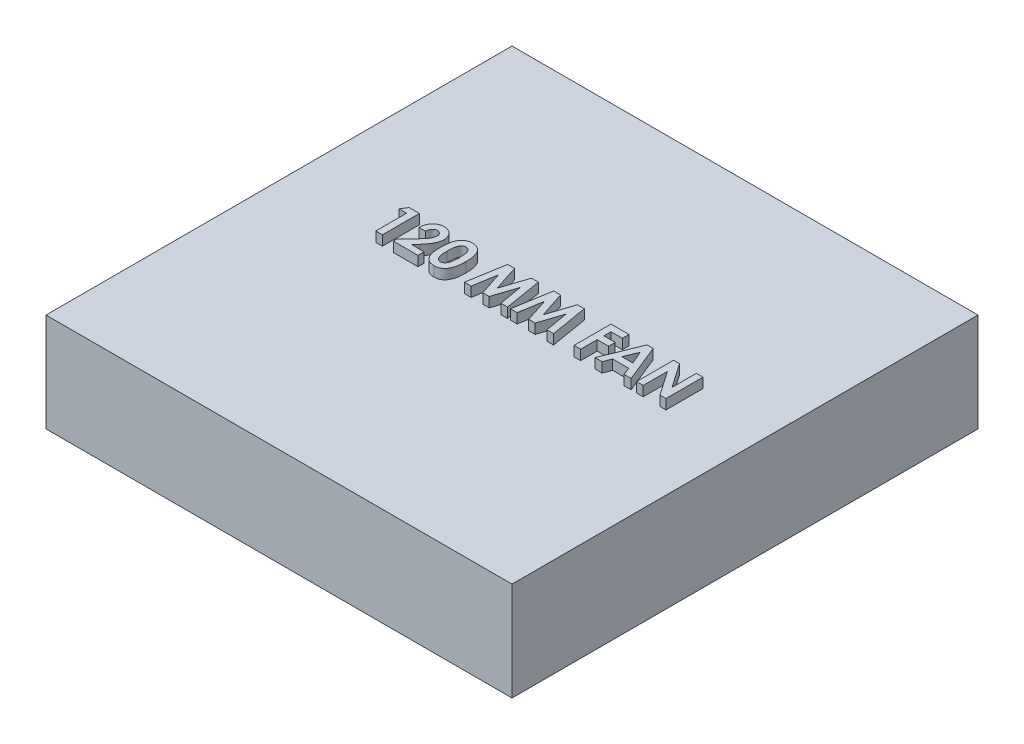
from build123d import *

# Parameters (mm, degrees)
SKETCH1_W           = 120
SKETCH1_H           = 120
BOSS_EXTRUDE1_DEPTH = 25.4
BOSS_EXTRUDE2_DEPTH = 2.54


with BuildPart() as part:
    # Sketch1 → Boss-Extrude1 (new body)
    with BuildSketch(Plane(origin=(0, 0, 0), x_dir=(1, 0, 0), z_dir=(0, 1, 0))):
        Rectangle(SKETCH1_W, SKETCH1_H)
    extrude(amount=BOSS_EXTRUDE1_DEPTH)

    # Sketch2 → Boss-Extrude2 (add)
    with BuildSketch(Plane(origin=(0, 25.4, 0), x_dir=(1, 0, 0), z_dir=(0, 1, 0))):
        Polygon((-34.68545046, 8.193229377), (-32.042797215, 8.193229377), (-32.042797215, -1.331770623), (-33.7524126, -1.331770623), (-33.7524126, 6.605729377), (-35.706258753, 6.605729377), align=None)
        with BuildLine():
            Line((-27.280297215, 5.018229377), (-28.9899126, 5.018229377))
            add(Edge.make_bspline(
                [(-28.9899126, 5.018229377), (-28.982529033, 5.147552736), (-28.968101987, 5.400242816), (-28.910714845, 5.767283247), (-28.833818044, 6.114096094), (-28.731189054, 6.439468166), (-28.602229014, 6.743281234), (-28.450256397, 7.026571013), (-28.271388648, 7.287845977), (-28.069432661, 7.52584611), (-27.847817093, 7.739358226), (-27.611142901, 7.92867148), (-27.355789834, 8.084888014), (-27.086423402, 8.213439758), (-26.803089471, 8.316146629), (-26.50310726, 8.384814483), (-26.189074174, 8.431317026), (-25.974093098, 8.435386185), (-25.864521975, 8.437460146)],
                knots=[0, 0, 0, 0, 0.000388391, 0.000758892, 0.001112999, 0.001453339, 0.001780797, 0.002101804, 0.00241617, 0.002728887, 0.003036551, 0.00333812, 0.003636247, 0.003932389, 0.004232342, 0.004538255, 0.004854238, 0.005182695, 0.005182695, 0.005182695, 0.005182695], degree=3))
            add(Edge.make_bspline(
                [(-25.864521975, 8.437460146), (-25.730024975, 8.433263485), (-25.467455314, 8.42507062), (-25.085920769, 8.355182757), (-24.72960922, 8.238284506), (-24.398779671, 8.074946822), (-24.096248533, 7.867443415), (-23.822065974, 7.620029563), (-23.584523711, 7.327514393), (-23.382115657, 7.002068984), (-23.213938756, 6.657468098), (-23.096087388, 6.301136492), (-23.018624953, 5.942529762), (-23.010363104, 5.701062141), (-23.006258753, 5.581104978)],
                knots=[0, 0, 0, 0, 0.00040325, 0.000787238, 0.001158922, 0.001524994, 0.001890166, 0.002256219, 0.002629032, 0.00301655, 0.003403998, 0.003776283, 0.004140381, 0.004499825, 0.004499825, 0.004499825, 0.004499825], degree=3))
            add(Edge.make_bspline(
                [(-23.006258753, 5.581104978), (-23.007856771, 5.508546407), (-23.011073186, 5.362503928), (-23.033437343, 5.141505812), (-23.066987999, 4.916393393), (-23.117574212, 4.687359684), (-23.180659366, 4.454340483), (-23.257190777, 4.216638444), (-23.348943665, 3.97560125), (-23.454386861, 3.728516069), (-23.580180861, 3.474580711), (-23.726650489, 3.209988588), (-23.89768338, 2.934974413), (-24.091213673, 2.647985366), (-24.308181299, 2.349474074), (-24.54964542, 2.040339745), (-24.812824939, 1.71949309), (-24.999610846, 1.505025107), (-25.095576662, 1.394836949)],
                knots=[0, 0, 0, 0, 0.000217652, 0.000438079, 0.000665834, 0.000900113, 0.001141261, 0.001389865, 0.001648918, 0.001914741, 0.002195484, 0.002498678, 0.002821681, 0.003166722, 0.003536928, 0.003928521, 0.004343355, 0.004781692, 0.004781692, 0.004781692, 0.004781692], degree=3))
            Line((-25.095576662, 1.394836949), (-26.089672215, 0.255729377))
            Line((-26.089672215, 0.255729377), (-22.884143369, 0.255729377))
            Line((-22.884143369, 0.255729377), (-22.884143369, -1.331770623))
            Line((-22.884143369, -1.331770623), (-29.234143369, -1.331770623))
            Line((-29.234143369, -1.331770623), (-29.234143369, -0.465514613))
            Line((-29.234143369, -0.465514613), (-26.414041205, 2.535852574))
            add(Edge.make_bspline(
                [(-26.414041205, 2.535852574), (-26.332392001, 2.623403387), (-26.174261705, 2.792963348), (-25.94925859, 3.04198019), (-25.745650646, 3.278291228), (-25.567659851, 3.5044127), (-25.405945475, 3.713010144), (-25.267718351, 3.910370949), (-25.151713808, 4.0947109), (-25.025774424, 4.316992687), (-24.906173408, 4.582103272), (-24.796432238, 4.887521537), (-24.7295374, 5.179431058), (-24.720303797, 5.369645577), (-24.715874138, 5.460897646)],
                knots=[0, 0, 0, 0, 0.00035914, 0.000695548, 0.001006812, 0.001294669, 0.001558753, 0.001798538, 0.002017175, 0.002211955, 0.002564574, 0.002888021, 0.003184801, 0.003458459, 0.003458459, 0.003458459, 0.003458459], degree=3))
            add(Edge.make_bspline(
                [(-24.715874138, 5.460897646), (-24.719186087, 5.549176983), (-24.725603519, 5.720232352), (-24.796125893, 5.963557703), (-24.905381601, 6.18386397), (-25.059338324, 6.374568151), (-25.245828134, 6.531282423), (-25.461334627, 6.647842096), (-25.704100791, 6.715096492), (-25.874284498, 6.72351434), (-25.961832672, 6.727844762)],
                knots=[0, 0, 0, 0, 0.000264146, 0.000511826, 0.000753314, 0.000997664, 0.001241477, 0.001479647, 0.001727327, 0.001989731, 0.001989731, 0.001989731, 0.001989731], degree=3))
            add(Edge.make_bspline(
                [(-25.961832672, 6.727844762), (-26.007061173, 6.726245052), (-26.096100743, 6.723095767), (-26.226981949, 6.702131827), (-26.351524821, 6.665185071), (-26.471115588, 6.615681618), (-26.584477948, 6.550064436), (-26.691325963, 6.469180805), (-26.792785414, 6.375086162), (-26.888390966, 6.268074729), (-26.975404498, 6.148649937), (-27.0526896, 6.01790249), (-27.116591513, 5.875913544), (-27.17285308, 5.724557572), (-27.216244693, 5.562208887), (-27.24783917, 5.389839127), (-27.27185834, 5.207728716), (-27.277433084, 5.082544932), (-27.280297215, 5.018229377)],
                knots=[0, 0, 0, 0, 0.000135687, 0.000267121, 0.000396334, 0.000524614, 0.000654544, 0.000788108, 0.000925832, 0.001069076, 0.001217916, 0.001368447, 0.001523833, 0.001684404, 0.001852422, 0.002027183, 0.002209888, 0.002402941, 0.002402941, 0.002402941, 0.002402941], degree=3))
        make_face()
        with BuildLine():
            add(Edge.make_bspline(
                [(-18.577668008, 8.437460146), (-18.494915528, 8.436231662), (-18.332202042, 8.433816135), (-18.092555705, 8.407654004), (-17.861710024, 8.36813032), (-17.638761903, 8.313008564), (-17.425316145, 8.240056882), (-17.219819247, 8.15273497), (-17.024717217, 8.046462613), (-16.837521881, 7.926422528), (-16.658305346, 7.790520135), (-16.491374957, 7.635584389), (-16.33368221, 7.465180369), (-16.188640572, 7.276731872), (-16.053038053, 7.071953036), (-15.927320219, 6.850811391), (-15.812449471, 6.612224595), (-15.707138382, 6.355762101), (-15.612968874, 6.077579645), (-15.533650014, 5.774486355), (-15.465620819, 5.446413015), (-15.408199378, 5.092542999), (-15.36479805, 4.71240593), (-15.335544681, 4.306254353), (-15.315469635, 3.874871267), (-15.313831249, 3.578946014), (-15.312989523, 3.426913271)],
                knots=[0, 0, 0, 0, 0.000248164, 0.000487957, 0.000722283, 0.000950429, 0.001176096, 0.001398325, 0.001619437, 0.001841731, 0.002064981, 0.002293191, 0.002524097, 0.002760726, 0.003005746, 0.003260398, 0.003523239, 0.003799617, 0.004091655, 0.004403597, 0.004738893, 0.005096494, 0.005478724, 0.005886284, 0.006317926, 0.006773987, 0.006773987, 0.006773987, 0.006773987], degree=3))
            add(Edge.make_bspline(
                [(-15.312989523, 3.426913271), (-15.313899202, 3.272978428), (-15.315666692, 2.973885789), (-15.334710156, 2.538557054), (-15.367503899, 2.129456572), (-15.409770843, 1.746626667), (-15.467664994, 1.390269506), (-15.535467093, 1.059462363), (-15.616037977, 0.754325147), (-15.713309398, 0.475545399), (-15.817983037, 0.2186325), (-15.933168006, -0.019489108), (-16.056856647, -0.239464391), (-16.186211917, -0.444611974), (-16.328325547, -0.628884211), (-16.476280465, -0.798547323), (-16.636518894, -0.947138622), (-16.802294176, -1.082315839), (-16.97967933, -1.199136082), (-17.166845029, -1.30130514), (-17.367128113, -1.384176381), (-17.576877762, -1.45625336), (-17.799669202, -1.507996854), (-18.031962307, -1.549053616), (-18.276379618, -1.571744101), (-18.442788769, -1.574559005), (-18.528058633, -1.576001392)],
                knots=[0, 0, 0, 0, 0.000461784, 0.000897239, 0.001306848, 0.00169287, 0.002052354, 0.002389518, 0.00270564, 0.002998294, 0.003274672, 0.003537513, 0.003791227, 0.00403152, 0.00426431, 0.004488683, 0.004706008, 0.004919071, 0.005129692, 0.005342275, 0.005557742, 0.005779183, 0.006006874, 0.006243079, 0.006486482, 0.006742275, 0.006742275, 0.006742275, 0.006742275], degree=3))
            add(Edge.make_bspline(
                [(-18.528058633, -1.576001392), (-18.613326196, -1.574531182), (-18.780364098, -1.571651062), (-19.025442339, -1.549222329), (-19.25896648, -1.507830532), (-19.483520558, -1.455856112), (-19.697541712, -1.384335858), (-19.902056166, -1.298985169), (-20.095491381, -1.197453595), (-20.27838295, -1.080361172), (-20.450106428, -0.946088393), (-20.613330397, -0.796071457), (-20.767693796, -0.630690616), (-20.910848376, -0.448093469), (-21.045138593, -0.250717308), (-21.169164014, -0.036308191), (-21.282850102, 0.194821705), (-21.389752979, 0.442994553), (-21.482638047, 0.713553229), (-21.565301445, 1.008913788), (-21.633017126, 1.331538303), (-21.687478608, 1.681323129), (-21.730960624, 2.057527231), (-21.763306246, 2.460332191), (-21.782455487, 2.889925627), (-21.784204442, 3.185206594), (-21.785104907, 3.337234786)],
                knots=[0, 0, 0, 0, 0.000255793, 0.000501095, 0.000737301, 0.000966847, 0.001191908, 0.00141339, 0.001631025, 0.001846441, 0.002063992, 0.002284114, 0.002510924, 0.002741869, 0.002979489, 0.003226572, 0.003484273, 0.003751849, 0.004036667, 0.004341747, 0.004671443, 0.005024974, 0.005403413, 0.005807317, 0.006237053, 0.006693113, 0.006693113, 0.006693113, 0.006693113], degree=3))
            add(Edge.make_bspline(
                [(-21.785104907, 3.337234786), (-21.783473798, 3.54846599), (-21.780326551, 3.956039319), (-21.740442327, 4.544864278), (-21.681902402, 5.089130954), (-21.595921119, 5.587928921), (-21.489606452, 6.043105583), (-21.353464985, 6.451662474), (-21.198477828, 6.819252895), (-21.066408859, 7.037015673), (-21.002803225, 7.141892238)],
                knots=[0, 0, 0, 0, 0.000633577, 0.001222495, 0.001769707, 0.002275057, 0.00274016, 0.00317037, 0.003565981, 0.003933523, 0.003933523, 0.003933523, 0.003933523], degree=3))
            add(Edge.make_bspline(
                [(-21.002803225, 7.141892238), (-20.928845622, 7.244922942), (-20.784243936, 7.446368271), (-20.531403846, 7.710828333), (-20.259760088, 7.937007528), (-19.963733255, 8.119787219), (-19.648005134, 8.263927297), (-19.309865039, 8.365731812), (-18.950561665, 8.425047865), (-18.703822044, 8.433260935), (-18.577668008, 8.437460146)],
                knots=[0, 0, 0, 0, 0.000380086, 0.000743143, 0.001094209, 0.001437839, 0.001783665, 0.002132552, 0.002494227, 0.002872604, 0.002872604, 0.002872604, 0.002872604], degree=3))
        make_face()
        with BuildLine():
            add(Edge.make_bspline(
                [(-18.535690845, 6.727844762), (-18.610499773, 6.724298967), (-18.757164984, 6.717347328), (-18.969983193, 6.658337717), (-19.170657476, 6.567194192), (-19.323305044, 6.457517209), (-19.43756023, 6.352378669), (-19.517391148, 6.257231709), (-19.594375486, 6.151054559), (-19.66237193, 6.02905599), (-19.726578323, 5.895619556), (-19.789327322, 5.750139533), (-19.840765024, 5.589042619), (-19.891301203, 5.415072314), (-19.935575611, 5.223418802), (-19.972667859, 5.012515527), (-20.005806522, 4.780990966), (-20.028921134, 4.528693468), (-20.05047089, 4.255887001), (-20.065918775, 3.961963856), (-20.072377148, 3.647003329), (-20.074430068, 3.430094688), (-20.075489523, 3.318154257)],
                knots=[0, 0, 0, 0, 0.000224056, 0.000439269, 0.000657822, 0.000882292, 0.000999742, 0.001122882, 0.001254191, 0.00139264, 0.001541126, 0.001698468, 0.001867414, 0.002047995, 0.002241923, 0.002457127, 0.002690269, 0.00294335, 0.003217008, 0.003511244, 0.003826166, 0.004162005, 0.004162005, 0.004162005, 0.004162005], degree=3))
            add(Edge.make_bspline(
                [(-20.075489523, 3.318154257), (-20.07374579, 3.173130017), (-20.070402052, 2.895035284), (-20.052889117, 2.495125376), (-20.017785893, 2.131175157), (-19.974124569, 1.800718003), (-19.912800457, 1.505897017), (-19.842243097, 1.243922918), (-19.75511103, 1.018135242), (-19.654413139, 0.825268589), (-19.542885686, 0.661197328), (-19.421817731, 0.521736017), (-19.295331202, 0.400969101), (-19.159478045, 0.302871624), (-19.014582363, 0.22769424), (-18.86185377, 0.173620075), (-18.701195208, 0.140519028), (-18.591177881, 0.135928976), (-18.535690845, 0.133613992)],
                knots=[0, 0, 0, 0, 0.000435103, 0.000834342, 0.001200395, 0.00153176, 0.001833745, 0.002103179, 0.002344832, 0.002558202, 0.002754546, 0.002938532, 0.003111314, 0.003278113, 0.003439408, 0.003599332, 0.003762858, 0.003929253, 0.003929253, 0.003929253, 0.003929253], degree=3))
            add(Edge.make_bspline(
                [(-18.535690845, 0.133613992), (-18.482107948, 0.135198076), (-18.377199299, 0.138299516), (-18.224218994, 0.170135374), (-18.079549947, 0.221893566), (-17.943628959, 0.295109161), (-17.815969861, 0.388213993), (-17.69719657, 0.501617203), (-17.588204851, 0.636449158), (-17.524705781, 0.73651441), (-17.491985917, 0.788076132)],
                knots=[0, 0, 0, 0, 0.00016056, 0.000314357, 0.000466451, 0.000620106, 0.00077582, 0.000939123, 0.001111366, 0.00129447, 0.00129447, 0.00129447, 0.00129447], degree=3))
            add(Edge.make_bspline(
                [(-17.491985917, 0.788076132), (-17.453463788, 0.858533578), (-17.372686007, 1.006277127), (-17.279209819, 1.255588859), (-17.200526774, 1.536771286), (-17.132805428, 1.850699476), (-17.086488158, 2.1986116), (-17.046599782, 2.578301517), (-17.027360627, 2.991681191), (-17.024231274, 3.278072121), (-17.022604907, 3.426913271)],
                knots=[0, 0, 0, 0, 0.000240657, 0.000504638, 0.000796345, 0.001116313, 0.001467104, 0.001848719, 0.002261393, 0.002707943, 0.002707943, 0.002707943, 0.002707943], degree=3))
            add(Edge.make_bspline(
                [(-17.022604907, 3.426913271), (-17.023233137, 3.577046434), (-17.024442373, 3.866027144), (-17.046628349, 4.280892948), (-17.077524015, 4.659804007), (-17.122715455, 5.001914366), (-17.180862457, 5.30805452), (-17.252528856, 5.578204456), (-17.33701821, 5.812896587), (-17.437212515, 6.011896894), (-17.548183932, 6.181019856), (-17.66598348, 6.32611424), (-17.791109261, 6.449992164), (-17.923352026, 6.553119803), (-18.065772579, 6.631917053), (-18.215650502, 6.687554431), (-18.373293056, 6.721213178), (-18.480827596, 6.725604397), (-18.535690845, 6.727844762)],
                knots=[0, 0, 0, 0, 0.000450337, 0.000866822, 0.001246006, 0.001590604, 0.00190157, 0.002180204, 0.002428317, 0.002648472, 0.002846928, 0.003034073, 0.003208124, 0.003374136, 0.003535555, 0.003694337, 0.003852256, 0.004016748, 0.004016748, 0.004016748, 0.004016748], degree=3))
        make_face(mode=Mode.SUBTRACT)
        Polygon((-9.308347095, 8.193229377), (-7.533857912, 8.193229377), (-5.360585677, 1.549389233), (-3.172049018, 8.193229377), (-1.414732311, 8.193229377), (0.195664323, -1.331770623), (-1.534939643, -1.331770623), (-2.55193183, 4.684320122), (-4.532490725, -1.331770623), (-6.200128946, -1.331770623), (-8.169239523, 4.684320122), (-9.184323657, -1.331770623), (-10.916835677, -1.331770623), align=None)
        Polygon((2.536845213, 8.193229377), (4.311334396, 8.193229377), (6.484606631, 1.549389233), (8.67314329, 8.193229377), (10.430459997, 8.193229377), (12.040856631, -1.331770623), (10.310252665, -1.331770623), (9.293260477, 4.684320122), (7.312701583, -1.331770623), (5.645063362, -1.331770623), (3.675952785, 4.684320122), (2.66086865, -1.331770623), (0.928356631, -1.331770623), align=None)
        Polygon((17.29181817, 8.193229377), (21.932202785, 8.193229377), (21.932202785, 6.483613992), (19.001433554, 6.483613992), (19.001433554, 4.651883223), (21.932202785, 4.651883223), (21.932202785, 2.942267839), (19.001433554, 2.942267839), (19.001433554, -1.331770623), (17.29181817, -1.331770623), align=None)
        Polygon((26.574495453, 8.193229377), (28.1600874, 8.193229377), (32.006722016, -1.331770623), (30.180715405, -1.331770623), (29.440390886, 0.622075531), (25.290375862, 0.622075531), (24.550051343, -1.331770623), (22.725952785, -1.331770623), align=None)
        Polygon((27.3663374, 5.638346565), (25.939113843, 2.331690916), (28.793560958, 2.331690916), align=None, mode=Mode.SUBTRACT)
        Polygon((33.411048939, 8.193229377), (34.950847617, 8.193229377), (39.2725874, 1.925275651), (39.2725874, 8.193229377), (40.982202785, 8.193229377), (40.982202785, -1.331770623), (39.43095579, -1.331770623), (35.120664323, 4.917102574), (35.120664323, -1.331770623), (33.411048939, -1.331770623), align=None)
    extrude(amount=BOSS_EXTRUDE2_DEPTH)


solid = part.part
